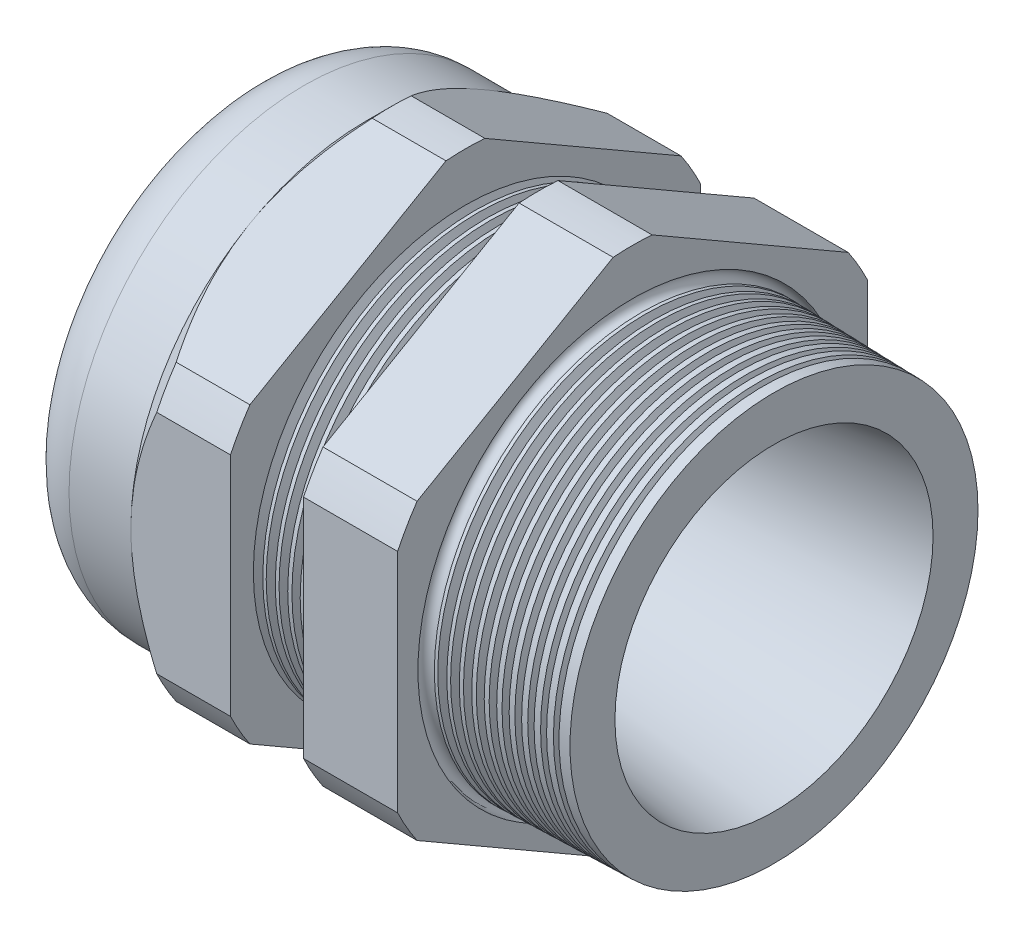
from build123d import *

# Parameters (mm, degrees)
LPATTERN6_COUNT    = 6
LPATTERN6_PITCH    = 1.5748
LPATTERN7_COUNT    = 11
LPATTERN7_PITCH    = 1.5748
SKETCH12_OUTSIDE_W = 158.354
SKETCH12_OUTSIDE_H = 158.354
CUT_EXTRUDE2_DEPTH = 53.05603
FILLET4_R          = 7.112
SKETCH19_OUTSIDE_W = 92.316
SKETCH19_OUTSIDE_H = 98.91
SKETCH19_OUTSIDE_R = 29.972
CUT_EXTRUDE3_DEPTH = 3.99796
CUT_EXTRUDE3_DRAFT = -45
SKETCH28_R         = 1.016


with BuildPart() as part:
    # Sketch10 → Revolve2 (revolve)
    with BuildSketch(Plane.XY, mode=Mode.PRIVATE) as revolve2_sk:
        Polygon((-41.89603, 15.494), (-29.19603, 15.494), (10.16, 20.28825), (10.16, 26.020426085), (-7.874, 26.492662995), (-7.874, 59.944), (-19.873976, 59.944), (-19.873976, 26.806893425), (-29.19603, 27.051), (-29.19603, 59.944), (-41.89603, 59.944), (-41.89603, 29.972), (-56.896, 29.972), (-56.896, 20.28825), (-41.89603, 20.28825), align=None)
    revolve(revolve2_sk.sketch.rotate(Axis((0, 0, 0), (-1, 0, 0)), 90), axis=Axis((0, 0, 0), (-1, 0, 0)))  # turned: the seam where the file's is

    # Sketch26 → Cut-Revolve1 (revolve, cut)
    with BuildSketch(Plane.XY, mode=Mode.PRIVATE) as cut_revolve1_sk:
        Polygon((-29.19603, 27.051), (-28.023256271, 27.020289839), (-28.636238915, 26.019993077), align=None)
    cut_revolve1 = revolve(cut_revolve1_sk.sketch.rotate(Axis((0, 0, 0), (-1, 0, 0)), 90), axis=Axis((0, 0, 0), (-1, 0, 0)), mode=Mode.SUBTRACT)  # turned: the seam where the file's is

    # LPattern6: Cut-Revolve1 ×6
    with Locations(*[(i * LPATTERN6_PITCH, 0, 0) for i in range(1, LPATTERN6_COUNT)]):
        add(cut_revolve1, mode=Mode.SUBTRACT)

    # Sketch27 → Cut-Revolve2 (revolve, cut)
    with BuildSketch(Plane.XY, mode=Mode.PRIVATE) as cut_revolve2_sk:
        Polygon((-7.874, 26.492662995), (-6.701226271, 26.461952834), (-7.314208915, 25.461656072), align=None)
    cut_revolve2 = revolve(cut_revolve2_sk.sketch.rotate(Axis((0, 0, 0), (-1, 0, 0)), 90), axis=Axis((0, 0, 0), (-1, 0, 0)), mode=Mode.SUBTRACT)  # turned: the seam where the file's is

    # LPattern7: Cut-Revolve2 ×11
    with Locations(*[(i * LPATTERN7_PITCH, 0, 0) for i in range(1, LPATTERN7_COUNT)]):
        add(cut_revolve2, mode=Mode.SUBTRACT)

    # Sketch12 outside → Cut-Extrude2 (cut, through all)
    with BuildSketch(Plane.ZY.offset(41.89603)):
        Rectangle(SKETCH12_OUTSIDE_W, SKETCH12_OUTSIDE_H)
        with BuildLine():
            Line((-2.480993384, 33.176282338), (-27.491006616, 18.736744466))
            ThreePointArc((-27.491006616, 18.736744466), (-28.811729876, 16.63446), (-29.972, 14.439537872))
            Line((-29.972, 14.439537872), (-29.972, -14.439537872))
            ThreePointArc((-29.972, -14.439537872), (-28.811729876, -16.63446), (-27.491006616, -18.736744466))
            Line((-27.491006616, -18.736744466), (-2.480993384, -33.176282338))
            ThreePointArc((-2.480993384, -33.176282338), (0, -33.26892), (2.480993384, -33.176282338))
            Line((2.480993384, -33.176282338), (27.491006616, -18.736744466))
            ThreePointArc((27.491006616, -18.736744466), (28.811729876, -16.63446), (29.972, -14.439537872))
            Line((29.972, -14.439537872), (29.972, 14.439537872))
            ThreePointArc((29.972, 14.439537872), (28.811729876, 16.63446), (27.491006616, 18.736744466))
            Line((27.491006616, 18.736744466), (2.480993384, 33.176282338))
            ThreePointArc((2.480993384, 33.176282338), (0, 33.26892), (-2.480993384, 33.176282338))
        make_face(mode=Mode.SUBTRACT)
    extrude(amount=-CUT_EXTRUDE2_DEPTH, mode=Mode.SUBTRACT)

    # Fillet4
    fillet4_edges = [part.edges().sort_by_distance(p)[0] for p in [
        (-56.896, 0, 29.972),
    ]]
    fillet(fillet4_edges, radius=FILLET4_R)


with BuildPart() as body_2:
    # Sketch30 → Revolve8 (revolve)
    with BuildSketch(Plane.XY, mode=Mode.PRIVATE) as revolve8_sk:
        with BuildLine():
            Line((-55.9054, 20.28825), (-41.89603, 20.28825))
            Line((-41.89603, 20.28825), (-41.89603, 15.494))
            Line((-41.89603, 15.494), (-56.134, 15.494))
            Line((-56.134, 15.494), (-56.134, 20.05965))
            ThreePointArc((-56.134, 20.05965), (-56.06704461, 20.22129461), (-55.9054, 20.28825))
        make_face()
    revolve(revolve8_sk.sketch.rotate(Axis((0, 0, 0), (-1, 0, 0)), 270), axis=Axis((0, 0, 0), (-1, 0, 0)))  # turned: the seam where the file's is


with BuildPart() as cut_extrude3_tool:
    # Sketch19 outside → Cut-Extrude3 (with draft: the straight prism first)
    with BuildSketch(Plane.ZY.offset(41.89603)):
        Rectangle(SKETCH19_OUTSIDE_W, SKETCH19_OUTSIDE_H)
        Circle(SKETCH19_OUTSIDE_R, mode=Mode.SUBTRACT)
    extrude(amount=-CUT_EXTRUDE3_DEPTH)
    # Cut-Extrude3: the draft: its side faces are tilted about the plane it starts from
    cut_extrude3_sides = [cut_extrude3_tool.faces().sort_by_distance(p)[0] for p in [
        (-39.89705, -49.455, 0),
        (-39.89705, 0, 46.158),
        (-39.89705, 49.455, 0),
        (-39.89705, 0, -46.158),
        (-39.89705, 0, -29.972),
    ]]
    draft(cut_extrude3_sides, Plane.ZY.offset(41.89603), CUT_EXTRUDE3_DRAFT)


with BuildPart() as part_1:
    add(part.part)

    # Cut-Extrude3: cut by cut_extrude3_tool
    add(cut_extrude3_tool.part, mode=Mode.SUBTRACT)

    # Sketch28 → Cut-Revolve3 (revolve, cut)
    with BuildSketch(Plane.XY, mode=Mode.PRIVATE) as cut_revolve3_sk:
        with Locations((-7.8486, -26.365662995)):
            Circle(SKETCH28_R)
    revolve(cut_revolve3_sk.sketch.rotate(Axis((10.16, 0, 0), (-1, 0, 0)), 90), axis=Axis((10.16, 0, 0), (-1, 0, 0)), mode=Mode.SUBTRACT)  # turned: the seam where the file's is


solid = Compound([body_2.part, part_1.part])
